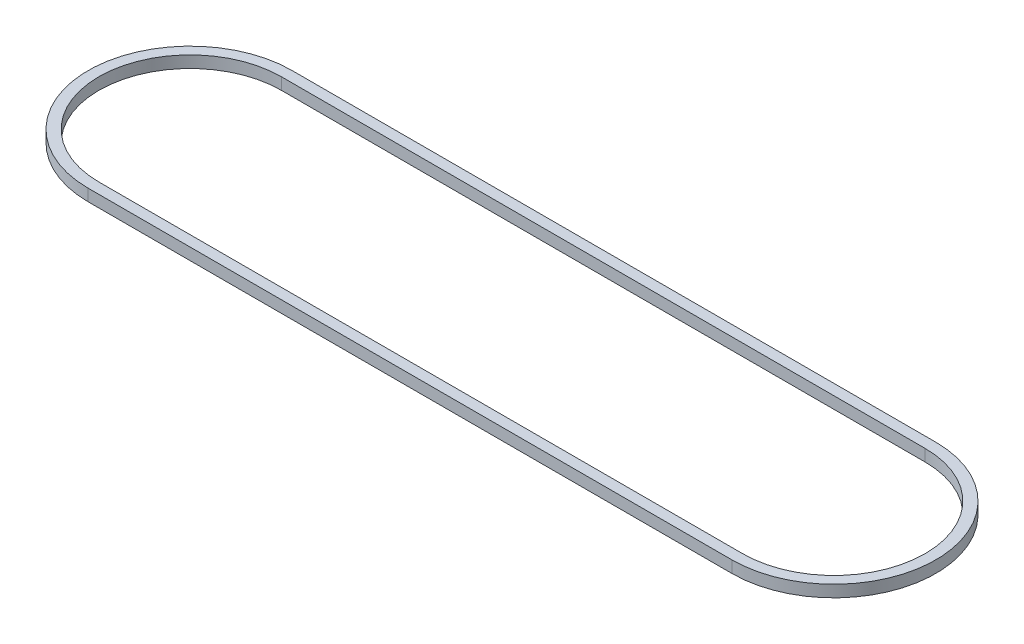
from build123d import *

# Parameters (mm, degrees)
BOSS_EXTRUDE1_DEPTH = 110
SHELL1_T            = -100
CUT_EXTRUDE1_DEPTH  = 110


with BuildPart() as part:
    # Sketch2 → Boss-Extrude1 (new body)
    with BuildSketch(Plane(origin=(0, 0, 0), x_dir=(1, 0, 0), z_dir=(0, 1, 0))):
        with BuildLine():
            Line((3000, 950), (-3000, 950))
            ThreePointArc((-3000, 950), (-3950, 0), (-3000, -950))
            Line((-3000, -950), (3000, -950))
            ThreePointArc((3000, -950), (3950, 0), (3000, 950))
        make_face()
    extrude(amount=BOSS_EXTRUDE1_DEPTH)

    # Shell1
    shell1_openings = [part.faces().sort_by_distance(p)[0] for p in [
        (0, 110, 0),
    ]]
    offset(amount=SHELL1_T, openings=shell1_openings, kind=Kind.INTERSECTION)

    # Sketch5 → Cut-Extrude1 (cut)
    with BuildSketch(Plane(origin=(0, 100, 0), x_dir=(1, 0, 0), z_dir=(0, 1, 0))):
        with BuildLine():
            Line((-3000, 850), (3000, 850))
            ThreePointArc((3000, 850), (3850, 0), (3000, -850))
            Line((3000, -850), (-3000, -850))
            ThreePointArc((-3000, -850), (-3850, 0), (-3000, 850))
        make_face()
    extrude(amount=-CUT_EXTRUDE1_DEPTH, mode=Mode.SUBTRACT)


solid = part.part
